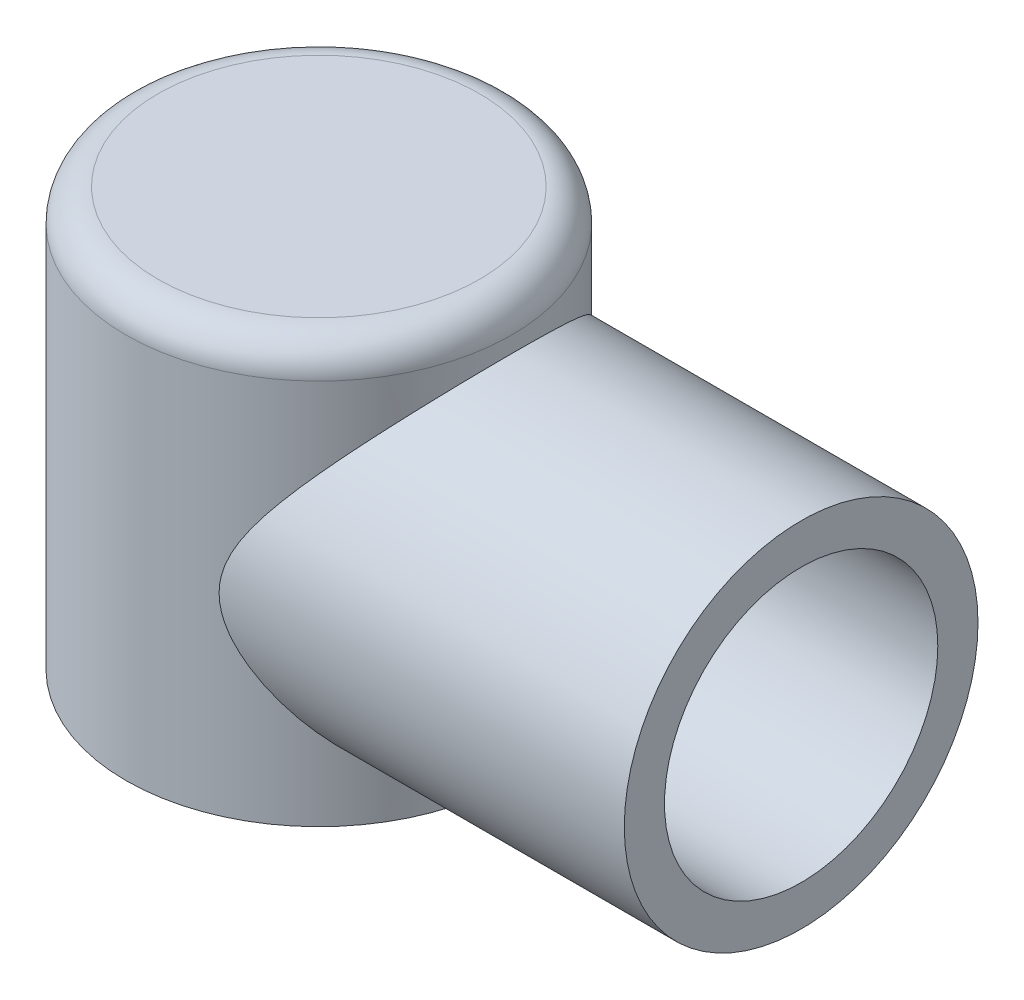
from build123d import *

# Parameters (mm, degrees)
SKETCH1_R           = 60
BOSS_EXTRUDE1_DEPTH = 130
FILLET1_R           = 10
SKETCH2_R           = 55
BOSS_EXTRUDE2_DEPTH = 150
SKETCH3_R           = 42.5
CUT_EXTRUDE1_DEPTH  = 150


with BuildPart() as part:
    # Sketch1 → Boss-Extrude1 (new body)
    with BuildSketch(Plane(origin=(0, 0, 0), x_dir=(1, 0, 0), z_dir=(0, 1, 0))):
        Circle(SKETCH1_R)
    extrude(amount=BOSS_EXTRUDE1_DEPTH)

    # Fillet1
    fillet1_edges = [part.edges().sort_by_distance(p)[0] for p in [
        (-60, 130, 0),
    ]]
    fillet(fillet1_edges, radius=FILLET1_R)

    # Sketch2 → Boss-Extrude2 (add)
    with BuildSketch(Plane(origin=(0, 0, 0), x_dir=(0, 0, -1), z_dir=(1, 0, 0))):
        with Locations((0, 60)):
            Circle(SKETCH2_R)
    extrude(amount=BOSS_EXTRUDE2_DEPTH)

    # Sketch3 → Cut-Extrude1 (cut)
    with BuildSketch(Plane(origin=(0, 0, 0), x_dir=(0, 0, -1), z_dir=(1, 0, 0))):
        with Locations((0, 60)):
            Circle(SKETCH3_R)
    extrude(amount=CUT_EXTRUDE1_DEPTH, mode=Mode.SUBTRACT)


solid = part.part
